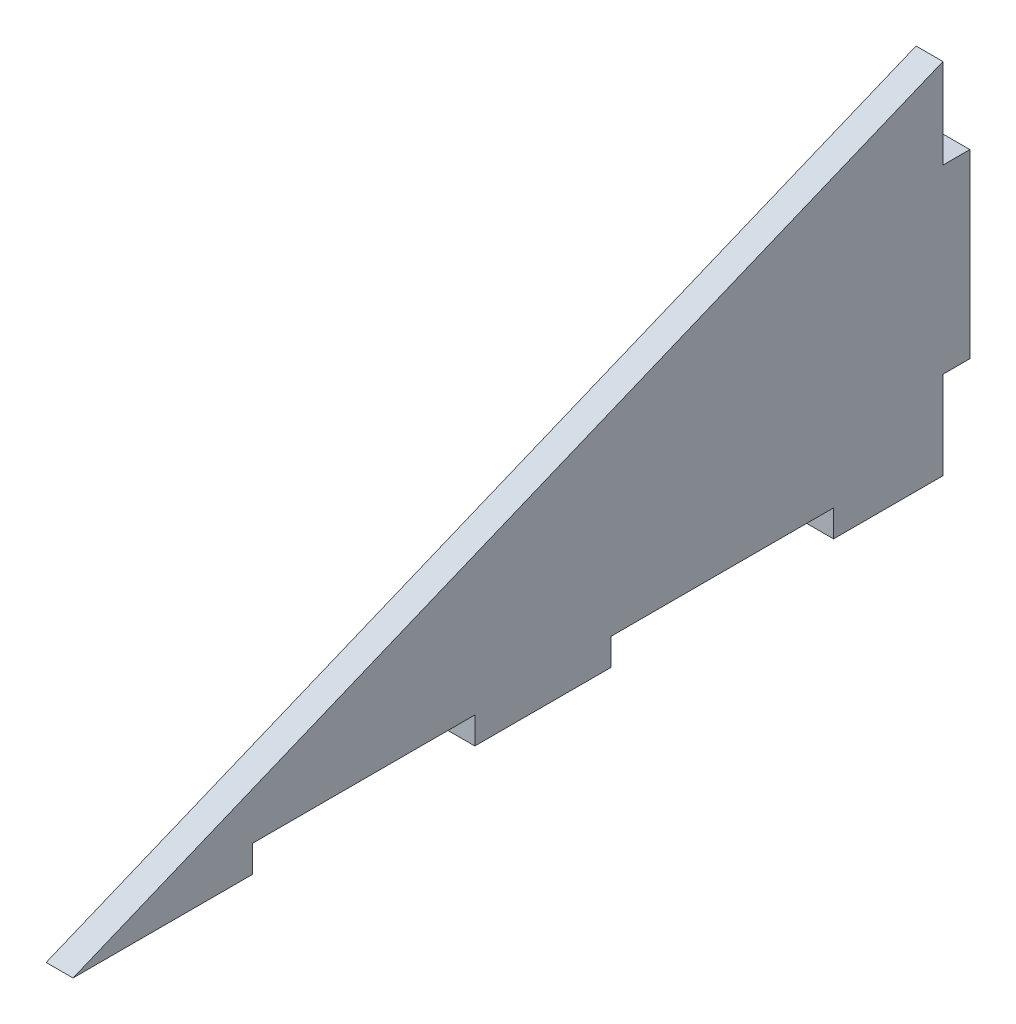
from build123d import *

# Parameters (mm, degrees)
BOSS_EXTRUDE1_DEPTH = 3


with BuildPart() as part:
    # Sketch1 → Boss-Extrude1 (new body)
    with BuildSketch(Plane(origin=(0, 0, 0), x_dir=(0, 0, -1), z_dir=(1, 0, 0))):
        Polygon((0, 30), (-3, 30), (-3, 40), (-100, 0), (-80, 0), (-80, 3), (-55.2, 3), (-55.2, 0), (-40, 0), (-40, 3), (-15.2, 3), (-15.2, 0), (-3, 0), (-3, 9.8), (0, 9.8), align=None)
    extrude(amount=BOSS_EXTRUDE1_DEPTH)


solid = part.part
